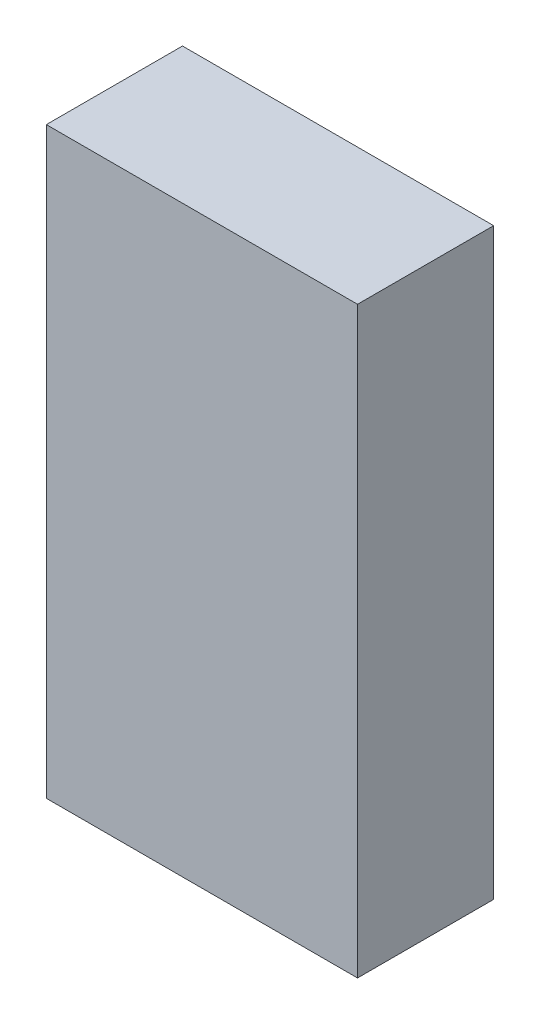
from build123d import *

# Parameters (mm, degrees)
EXTRUDE_1_DEPTH = 7


with BuildPart() as part:
    # 草图1 → 凸台-拉伸1 (new body)
    with BuildSketch(Plane.XY):
        Polygon((0, 0), (8, 0), (8, 30), (-1.5, 30), (-8, 30), (-8, 0), align=None)
    extrude(amount=-EXTRUDE_1_DEPTH)


solid = part.part
